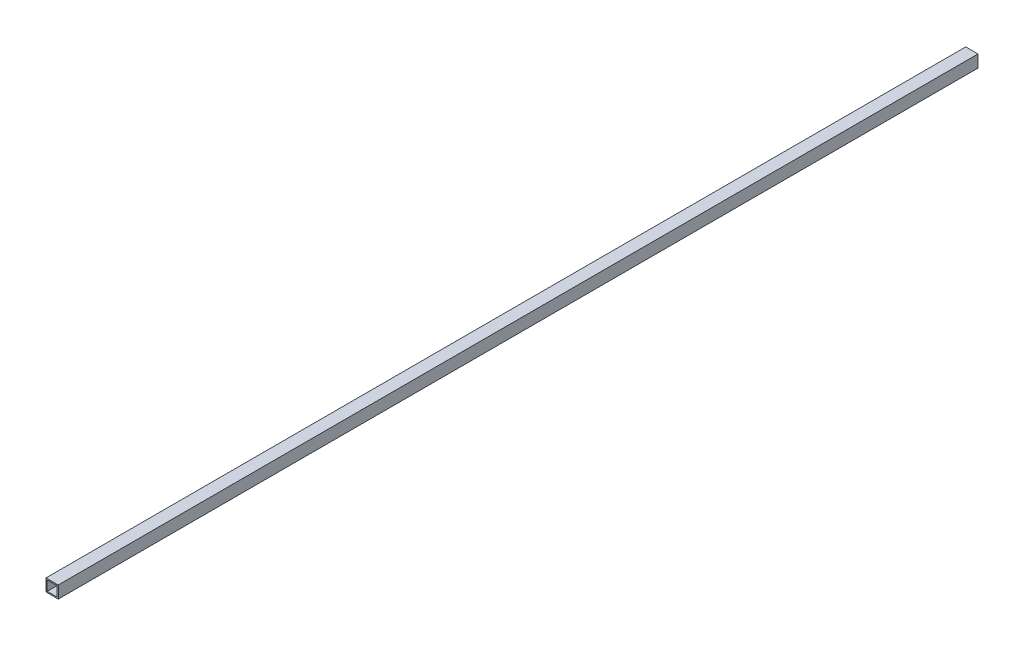
from build123d import *

# Parameters (mm, degrees)
SKETCH1_W           = 20
SKETCH1_H           = 20
SKETCH1_W_2         = 16
SKETCH1_H_2         = 16
BOSS_EXTRUDE1_DEPTH = 1500


with BuildPart() as part:
    # Sketch1 → Boss-Extrude1 (new body)
    with BuildSketch(Plane.XY):
        Rectangle(SKETCH1_W, SKETCH1_H)
        Rectangle(SKETCH1_W_2, SKETCH1_H_2, mode=Mode.SUBTRACT)
    extrude(amount=BOSS_EXTRUDE1_DEPTH)


solid = part.part
